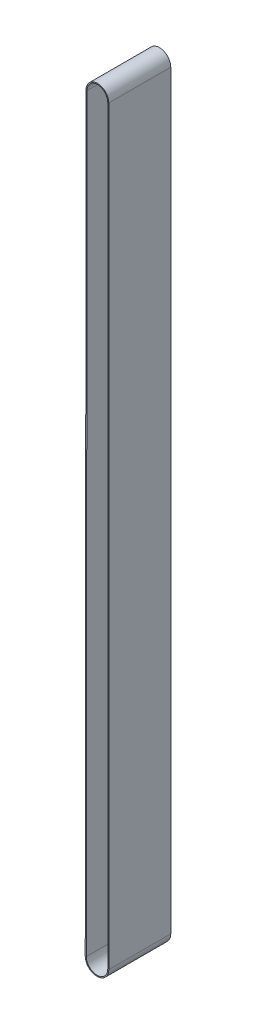
from build123d import *

# Parameters (mm, degrees)
EXTRUDE_THIN3_DEPTH = 300


with BuildPart() as part:
    # Sketch1 → Extrude-Thin3 (new body, symmetric)
    with BuildSketch(Plane.XY):
        with BuildLine():
            Line((114, -3670), (114, 3595))
            ThreePointArc((114, 3595), (4.002818531, 3704.999999964), (-105.999999856, 3595.005637062))
            Line((-105.999999856, 3595.005637062), (-113.999930882, -3669.874465707))
            ThreePointArc((-113.999930882, -3669.874465707), (-0.062767156, -3783.999982721), (114, -3670))
        make_face()
        with BuildLine():
            Line((104, -3670), (104, 3595))
            ThreePointArc((104, 3595), (4, 3695), (-96, 3595))
            Line((-96, 3595), (-103.999936945, -3669.885477488))
            ThreePointArc((-103.999936945, -3669.885477488), (-0.057261265, -3773.999984236), (104, -3670))
        make_face(mode=Mode.SUBTRACT)
    extrude(amount=EXTRUDE_THIN3_DEPTH, both=True)


solid = part.part
